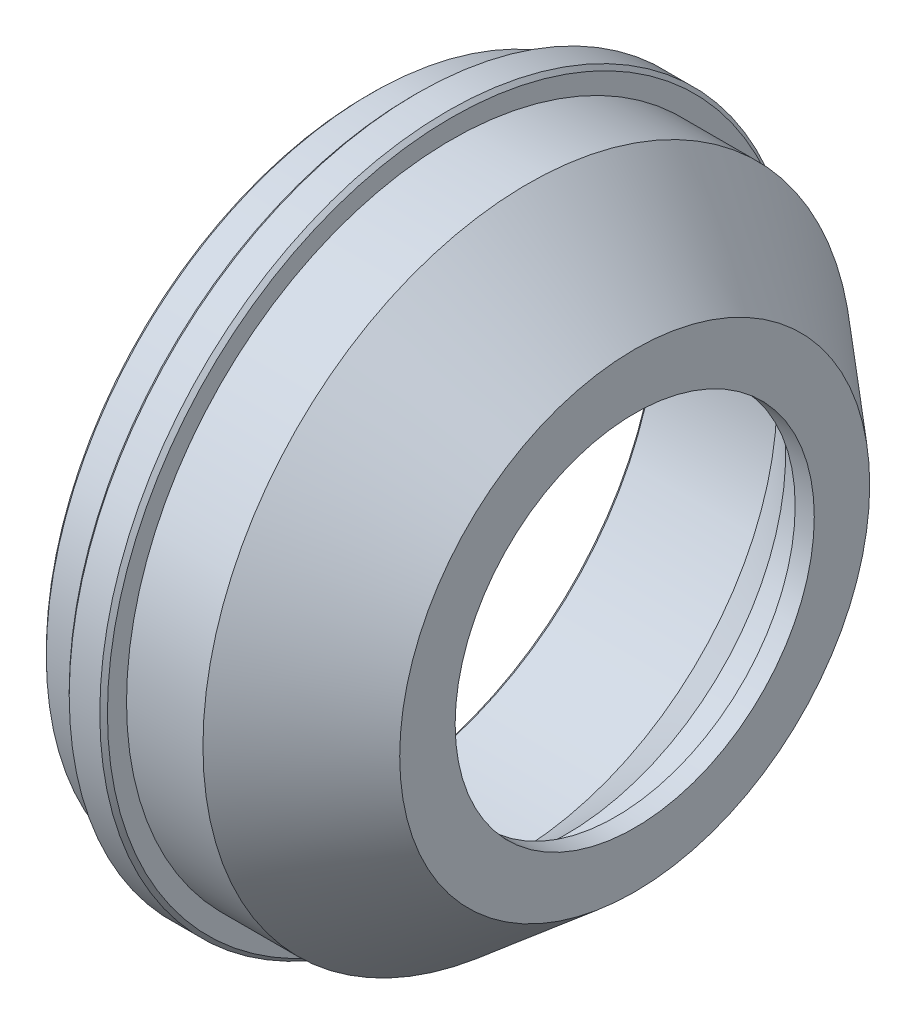
from build123d import *

# Parameters (mm, degrees)
ZAOKR_GLENIE1_R  = 1
ZAOKR_GLENIE2_R  = 1
SFAZOWANIE1_SIZE = 1


with BuildPart() as part:
    # Szkic1 → Obrót1 (revolve)
    with BuildSketch(Plane.XY, mode=Mode.PRIVATE) as obr_t1_sk:
        Polygon((70, 47), (65, 47), (65, 57.5), (52, 57.5), (38, 69.247394836), (38, 75), (0, 75), (0, 85), (12, 85), (12, 91), (22, 91), (22, 85), (42, 85), (70, 61.505210327), align=None)
    revolve(obr_t1_sk.sketch.rotate(Axis((0, 0, 0), (1, 0, 0)), 90), axis=Axis((0, 0, 0), (1, 0, 0)))  # turned: the seam where the file's is

    # Zaokrąglenie1
    zaokr_glenie1_edges = [part.edges().sort_by_distance(p)[0] for p in [
        (65, 0, -57.5),
    ]]
    fillet(zaokr_glenie1_edges, radius=ZAOKR_GLENIE1_R)

    # Zaokrąglenie2
    zaokr_glenie2_edges = [part.edges().sort_by_distance(p)[0] for p in [
        (38, 0, -75),
    ]]
    fillet(zaokr_glenie2_edges, radius=ZAOKR_GLENIE2_R)

    # Sfazowanie1
    sfazowanie1_edges = [part.edges().sort_by_distance(p)[0] for p in [
        (22, 0, -91),
        (12, 0, -91),
        (0, 0, -85),
        (0, 0, -75),
    ]]
    chamfer(sfazowanie1_edges, length=SFAZOWANIE1_SIZE)


solid = part.part
